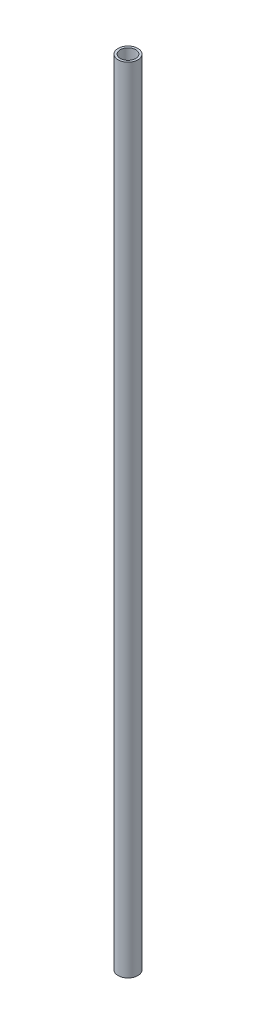
from build123d import *

# Parameters (mm, degrees)
SKETCH1_R           = 1.5875
BOSS_EXTRUDE1_DEPTH = 127
SKETCH2_R           = 1.2319
CUT_EXTRUDE1_DEPTH  = 128


with BuildPart() as part:
    # Sketch1 → Boss-Extrude1 (new body)
    with BuildSketch(Plane(origin=(0, 0, 0), x_dir=(1, 0, 0), z_dir=(0, 1, 0))):
        Circle(SKETCH1_R)
    extrude(amount=BOSS_EXTRUDE1_DEPTH)

    # Sketch2 → Cut-Extrude1 (cut, through all)
    with BuildSketch(Plane(origin=(0, 127, 0), x_dir=(1, 0, 0), z_dir=(0, 1, 0))):
        Circle(SKETCH2_R)
    extrude(amount=-CUT_EXTRUDE1_DEPTH, mode=Mode.SUBTRACT)


solid = part.part
